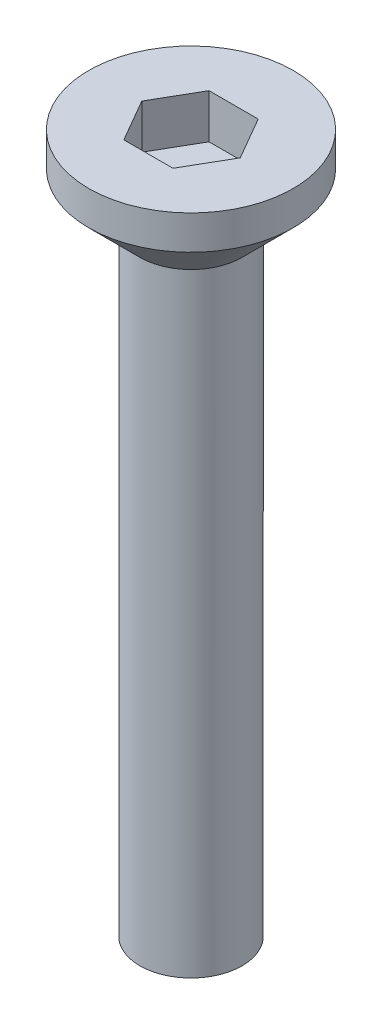
from build123d import *

# Parameters (mm, degrees)
SKETCH_1_R            = 3
EXTRUDE_251_DEPTH     = 2.5
CHAMFER_1_SIZE        = 1.5
CUT_EXTRUDE_459_DEPTH = 1.3
SKETCH_3_R            = 1.5
EXTRUDE_571_DEPTH     = 18


with BuildPart() as part:
    # 草图1 → Extrude 251 (new body)
    with BuildSketch(Plane(origin=(0, 0, 0), x_dir=(1, 0, 0), z_dir=(0, 1, 0))):
        Circle(SKETCH_1_R)
    extrude(amount=EXTRUDE_251_DEPTH)

    # 倒角1
    chamfer_1_edges = [part.edges().sort_by_distance(p)[0] for p in [
        (-3, 0, 0),
    ]]
    chamfer(chamfer_1_edges, length=CHAMFER_1_SIZE)

    # 草图2 → Cut-Extrude 459 (cut)
    with BuildSketch(Plane(origin=(0, 2.5, 0), x_dir=(1, 0, 0), z_dir=(0, 1, 0))):
        Polygon((1.443375673, 0), (0.721687836, 1.25), (-0.721687836, 1.25), (-1.443375673, 0), (-0.721687836, -1.25), (0.721687836, -1.25), align=None)
    extrude(amount=-CUT_EXTRUDE_459_DEPTH, mode=Mode.SUBTRACT)

    # 草图3 → Extrude 571 (add)
    with BuildSketch(Plane.XZ):
        Circle(SKETCH_3_R)
    extrude(amount=EXTRUDE_571_DEPTH)


solid = part.part
